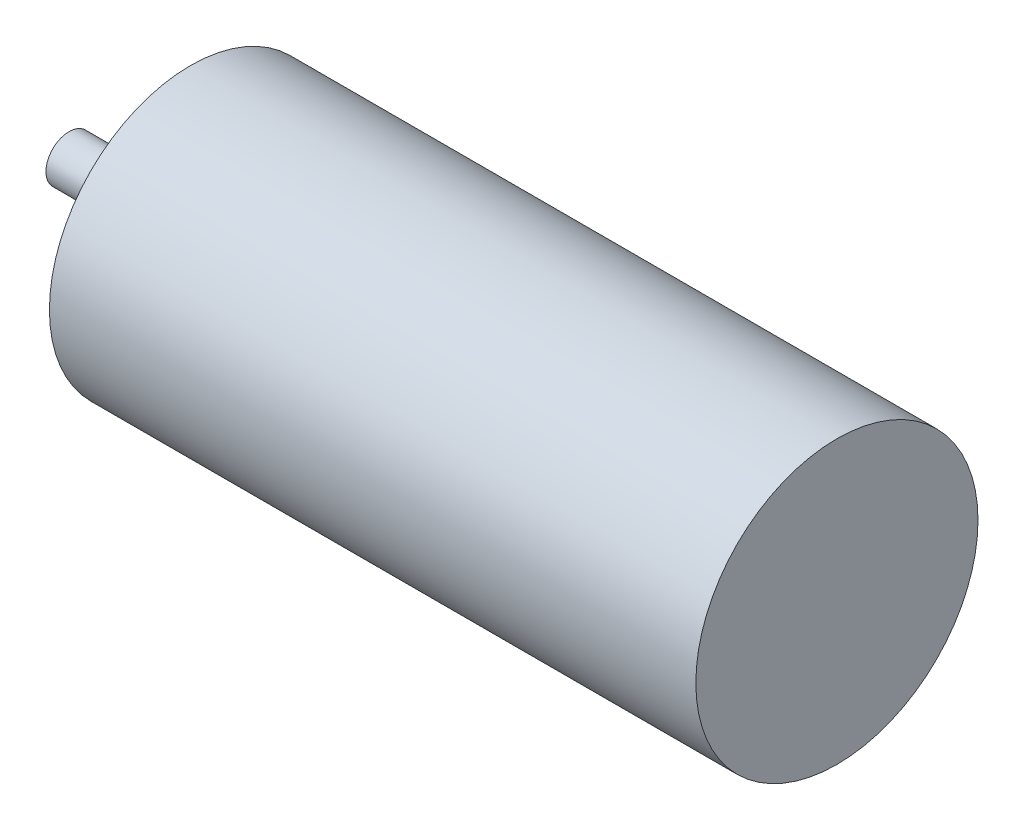
from build123d import *

# Parameters (mm, degrees)
SKICA2_W   = 8.5
SKICA2_H   = 2
SKICA2_W_2 = 55.9
SKICA2_H_2 = 12.2


with BuildPart() as part:
    # Skica2 → Rotovat1 (revolve)
    with BuildSketch(Plane.XY):
        with Locations((-62.15, 1)):
            Rectangle(SKICA2_W, SKICA2_H)
        Polygon((-57.9, 0), (-55.9, 0), (-55.9, 3.5), (-57.9, 3.5), (-57.9, 2), align=None)
        with Locations((-27.95, 6.1)):
            Rectangle(SKICA2_W_2, SKICA2_H_2)
    revolve(axis=Axis((0, 0, 0), (-1, 0, 0)))


solid = part.part
